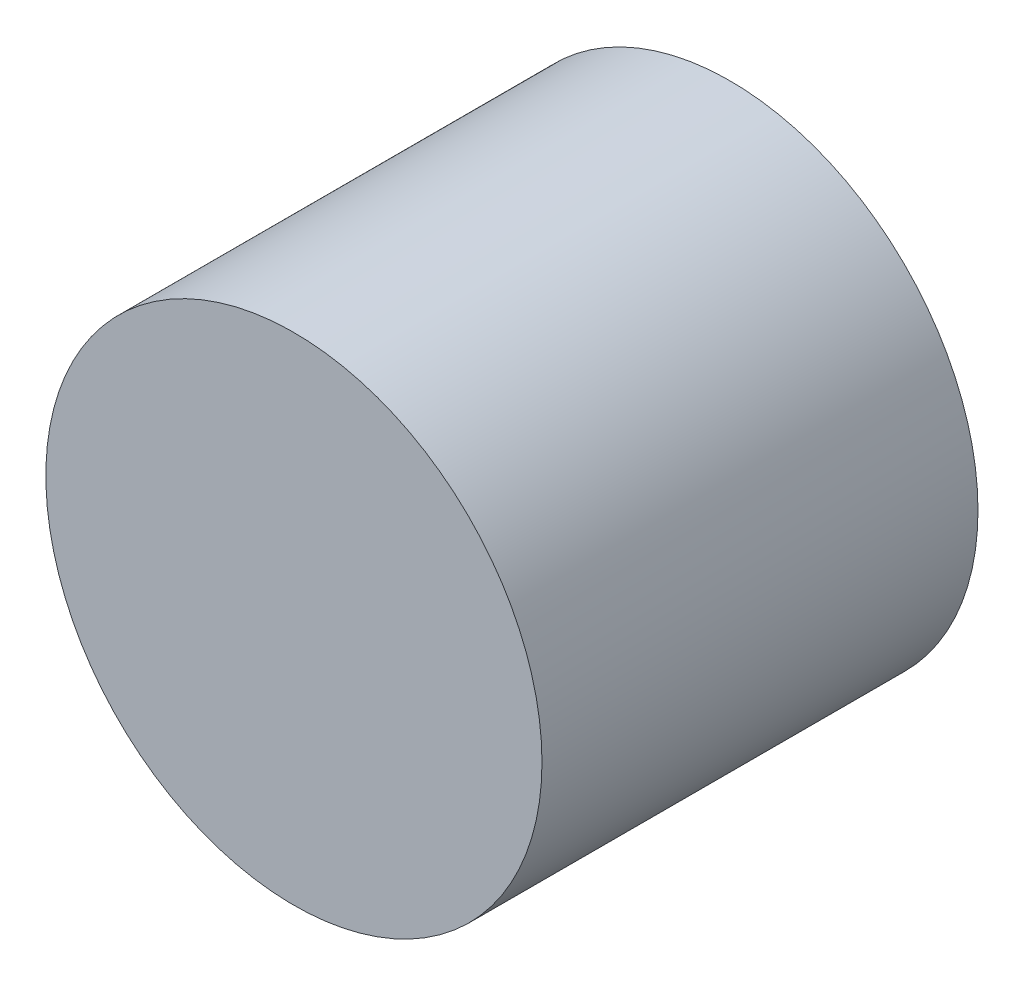
from build123d import *

# Parameters (mm, degrees)
SKETCH1_R           = 16.5
BOSS_EXTRUDE2_DEPTH = 14.5


with BuildPart() as part:
    # Sketch1 → Boss-Extrude2 (new body, symmetric)
    with BuildSketch(Plane.XY):
        Circle(SKETCH1_R)
    extrude(amount=BOSS_EXTRUDE2_DEPTH, both=True)


solid = part.part
